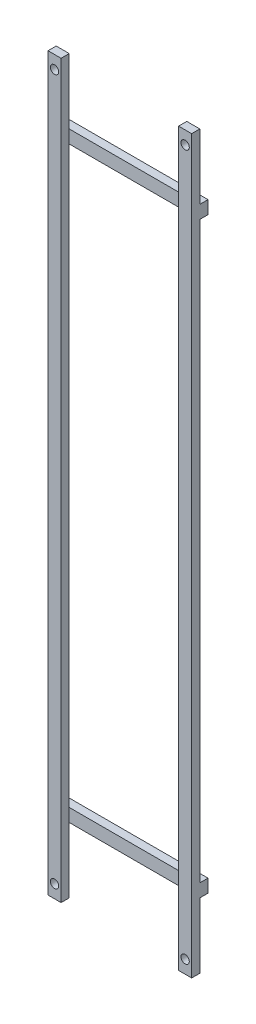
from build123d import *

# Parameters (mm, degrees)
SKETCH1_W            = 510
SKETCH1_H            = 80
BOSS_EXTRUDE1_DEPTH  = 10
SKETCH2_W            = 70
SKETCH2_H            = 390
CUT_EXTRUDE1_DEPTH   = 11
SKETCH3_W            = 70
SKETCH3_H            = 50
CUT_EXTRUDE2_DEPTH   = 11
SKETCH4_W            = 70
SKETCH4_H            = 10
BOSS_EXTRUDE2_DEPTH  = 100
SKETCH5_W            = 70
SKETCH5_H            = 50
CUT_EXTRUDE3_DEPTH   = 11
SKETCH6_W            = 70
SKETCH6_H            = 10
BOSS_EXTRUDE3_DEPTH  = 100
SKETCH7_W            = 10
SKETCH7_H            = 460
BOSS_EXTRUDE4_DEPTH  = 10
SKETCH8_W            = 10
SKETCH8_H            = 10
BOSS_EXTRUDE5_DEPTH  = 50
SKETCH9_W            = 90
SKETCH9_H            = 60
CUT_EXTRUDE4_DEPTH   = 61
SKETCH10_W           = 90
SKETCH10_H           = 60
CUT_EXTRUDE5_DEPTH   = 61
HOLE1_D              = 6.35
HOLE1_DEPTH          = 10
HOLE2_D              = 6.35
HOLE2_DEPTH          = 80
SCALE1_SCALE         = 4
SKETCH16_W           = 420.354500644
SKETCH16_H           = 2047.440969125
SKETCH16_W_2         = 504.269615058
SKETCH16_H_2         = 2143.883100275
CUT_EXTRUDE6_DEPTH   = 600
SKETCH17_W           = 706.747089412
SKETCH17_H           = 1090.886123918
CUT_EXTRUDE7_DEPTH   = 100
SKETCH18_W           = 40
SKETCH18_H           = 25
BOSS_EXTRUDE6_DEPTH  = 1
SKETCH20_W           = 40
SKETCH20_H           = 1219
SKETCH20_R           = 12.7
BOSS_EXTRUDE9_DEPTH  = 25
SKETCH21_W           = 440
SKETCH21_H           = 40
BOSS_EXTRUDE10_DEPTH = 25


with BuildPart() as part:
    # Sketch1 → Boss-Extrude1 (new body)
    with BuildSketch(Plane(origin=(45, 0, 0), x_dir=(0, -1, 0), z_dir=(-1, 0, 0))):
        with Locations((217.383525535, 40)):
            Rectangle(SKETCH1_W, SKETCH1_H)
    extrude(amount=-BOSS_EXTRUDE1_DEPTH)

    # Sketch2 → Cut-Extrude1 (cut, through all)
    with BuildSketch(Plane.ZY.offset(-45)):
        with Locations((35, -217.383525535)):
            Rectangle(SKETCH2_W, SKETCH2_H)
    extrude(amount=-CUT_EXTRUDE1_DEPTH, mode=Mode.SUBTRACT)

    # Sketch3 → Cut-Extrude2 (cut, through all)
    with BuildSketch(Plane.ZY.offset(-45)):
        with Locations((35, 12.616474465)):
            Rectangle(SKETCH3_W, SKETCH3_H)
    extrude(amount=-CUT_EXTRUDE2_DEPTH, mode=Mode.SUBTRACT)

    # Sketch4 → Boss-Extrude2 (add)
    with BuildSketch(Plane.ZY.offset(-45)):
        with Locations((35, -17.383525535)):
            Rectangle(SKETCH4_W, SKETCH4_H)
    extrude(amount=BOSS_EXTRUDE2_DEPTH)

    # Sketch5 → Cut-Extrude3 (cut, through all)
    with BuildSketch(Plane.ZY.offset(-45)):
        with Locations((35, -447.383525535)):
            Rectangle(SKETCH5_W, SKETCH5_H)
    extrude(amount=-CUT_EXTRUDE3_DEPTH, mode=Mode.SUBTRACT)

    # Sketch6 → Boss-Extrude3 (add)
    with BuildSketch(Plane.ZY.offset(-45)):
        with Locations((35, -417.383525535)):
            Rectangle(SKETCH6_W, SKETCH6_H)
    extrude(amount=BOSS_EXTRUDE3_DEPTH)

    # Sketch7 → Boss-Extrude4 (add)
    with BuildSketch(Plane.XY.offset(70)):
        with Locations((-50, -242.383525535)):
            Rectangle(SKETCH7_W, SKETCH7_H)
    extrude(amount=BOSS_EXTRUDE4_DEPTH)

    # Sketch8 → Boss-Extrude5 (add)
    with BuildSketch(Plane(origin=(0, -12.383525535, 0), x_dir=(-1, 0, 0), z_dir=(0, 1, 0))):
        with Locations((50, 75)):
            Rectangle(SKETCH8_W, SKETCH8_H)
    extrude(amount=BOSS_EXTRUDE5_DEPTH)

    # Sketch9 → Cut-Extrude4 (cut, through all)
    with BuildSketch(Plane.XZ.offset(22.383525535)):
        with Locations((0, 30)):
            Rectangle(SKETCH9_W, SKETCH9_H)
    extrude(amount=-CUT_EXTRUDE4_DEPTH, mode=Mode.SUBTRACT)

    # Sketch10 → Cut-Extrude5 (cut, through all)
    with BuildSketch(Plane(origin=(0, -412.383525535, 0), x_dir=(-1, 0, 0), z_dir=(0, 1, 0))):
        with Locations((0, 30)):
            Rectangle(SKETCH10_W, SKETCH10_H)
    extrude(amount=-CUT_EXTRUDE5_DEPTH, mode=Mode.SUBTRACT)

    # Hole1
    with Locations(Plane(origin=(0, 0, 70), x_dir=(-1, 0, 0), z_dir=(0, 0, -1))):
        with Locations((-50, 27.616474465), (50, -462.383525535)):
            Hole(HOLE1_D / 2, depth=HOLE1_DEPTH)

    # Hole2
    with Locations(Plane.XY.offset(80)):
        with Locations((50, -462.383525535), (-50, 27.616474465)):
            Hole(HOLE2_D / 2, depth=HOLE2_DEPTH)


with BuildPart() as part_1:
    # Scale1: scaled about (0, -217.383525535, 66.140384571)
    add(part.part.scale(SCALE1_SCALE).moved(Location((0, 652.150576605, -198.421153713))))

    # Sketch16 → Cut-Extrude6 (cut)
    with BuildSketch(Plane(origin=(220, 0, 0), x_dir=(0, 0, -1), z_dir=(1, 0, 0))):
        with Locations((153.598404035, -157.332882586)):
            Rectangle(SKETCH16_W, SKETCH16_H)
        with Locations((-358.713653816, -248.900281802)):
            Rectangle(SKETCH16_W_2, SKETCH16_H_2)
    extrude(amount=-CUT_EXTRUDE6_DEPTH, mode=Mode.SUBTRACT)

    # Sketch17 → Cut-Extrude7 (cut)
    with BuildSketch(Plane.XY.offset(106.578846287)):
        with Locations((133.373544706, 328.059536424)):
            Rectangle(SKETCH17_W, SKETCH17_H)
    extrude(amount=-CUT_EXTRUDE7_DEPTH, mode=Mode.SUBTRACT)

    # Sketch18 → Boss-Extrude6 (add)
    with BuildSketch(Plane(origin=(0, -217.383525535, 0), x_dir=(1, 0, 0), z_dir=(0, 1, 0))):
        with Locations((-200, -94.078846287)):
            Rectangle(SKETCH18_W, SKETCH18_H)
        with Locations((200, -94.078846287)):
            Rectangle(SKETCH18_W, SKETCH18_H)
    extrude(amount=BOSS_EXTRUDE6_DEPTH)

    # Sketch20 → Boss-Extrude9 (add)
    with BuildSketch(Plane.XY.offset(106.578846287)):
        with Locations((-200, 393.116474465)):
            Rectangle(SKETCH20_W, SKETCH20_H)
        with Locations((-200, 962.616474465)):
            Circle(SKETCH20_R, mode=Mode.SUBTRACT)
        with Locations((200, 393.116474465)):
            Rectangle(SKETCH20_W, SKETCH20_H)
        with Locations((200, 962.616474465)):
            Circle(SKETCH20_R, mode=Mode.SUBTRACT)
    extrude(amount=-BOSS_EXTRUDE9_DEPTH)

    # Sketch21 → Boss-Extrude10 (add)
    with BuildSketch(Plane(origin=(0, 0, 81.578846287), x_dir=(-1, 0, 0), z_dir=(0, 0, -1))):
        with Locations((0, 782.616474465)):
            Rectangle(SKETCH21_W, SKETCH21_H)
    extrude(amount=BOSS_EXTRUDE10_DEPTH)


solid = part_1.part
